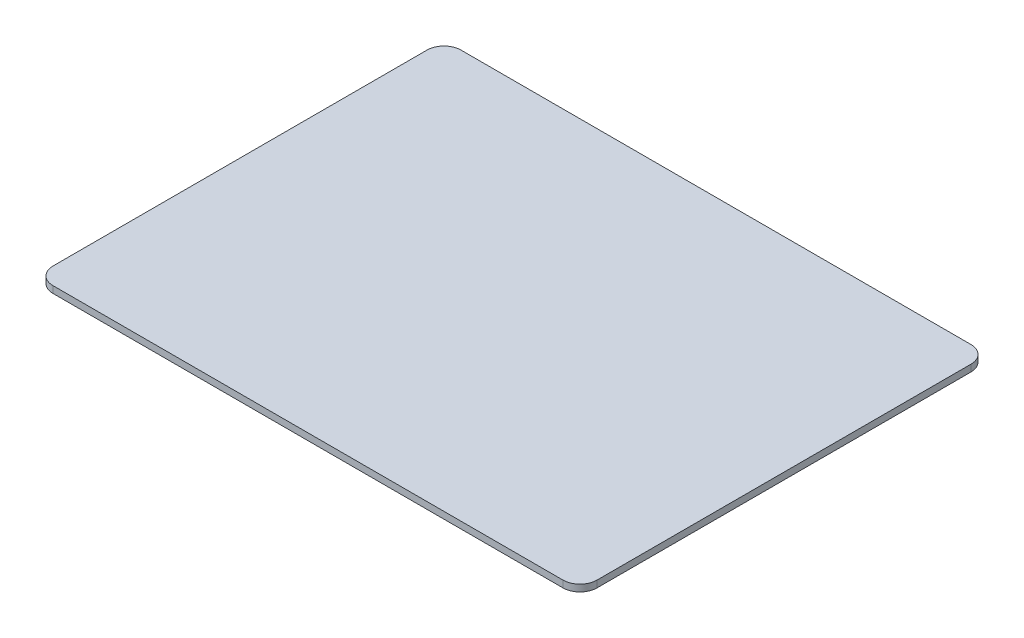
from build123d import *

# Parameters (mm, degrees)
BOSS_EXTRUDE1_DEPTH = 4


with BuildPart() as part:
    # Sketch2 → Boss-Extrude1 (new body)
    with BuildSketch(Plane(origin=(0, 0, 0), x_dir=(1, 0, 0), z_dir=(0, 1, 0))):
        with BuildLine():
            Line((10, 0), (310, 0))
            ThreePointArc((310, 0), (317.071067812, 2.928932188), (320, 10))
            Line((320, 10), (320, 230))
            ThreePointArc((320, 230), (317.071067812, 237.071067812), (310, 240))
            Line((310, 240), (10, 240))
            ThreePointArc((10, 240), (2.928932188, 237.071067812), (0, 230))
            Line((0, 230), (0, 10))
            ThreePointArc((0, 10), (2.928932188, 2.928932188), (10, 0))
        make_face()
    extrude(amount=BOSS_EXTRUDE1_DEPTH)


solid = part.part
